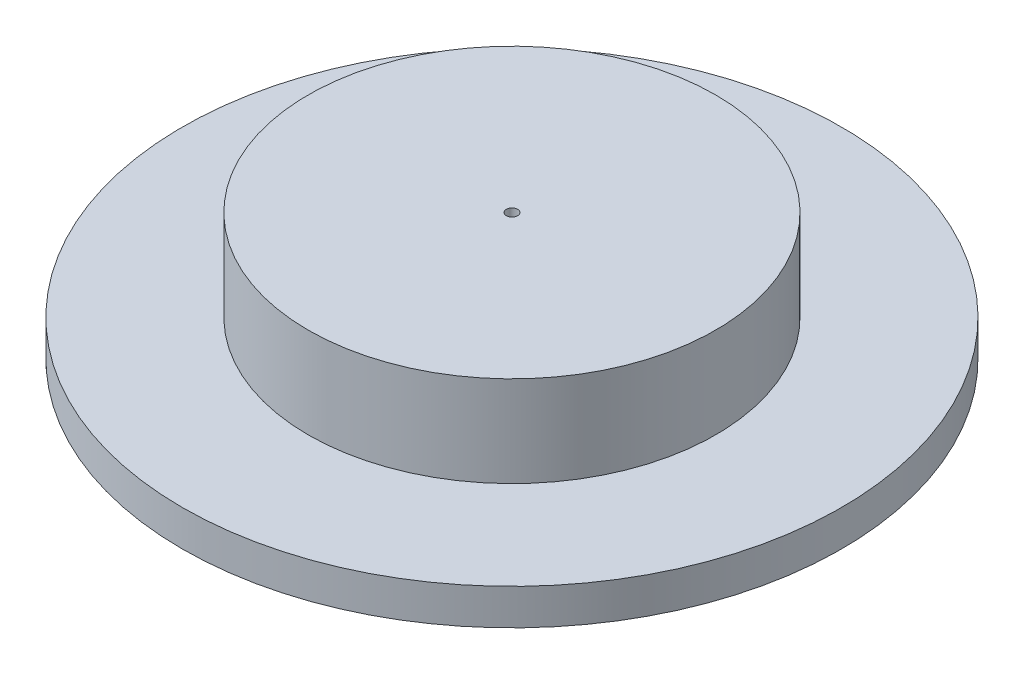
from build123d import *

# Parameters (mm, degrees)
SKETCH1_R                = 69.85
BOSS_EXTRUDE1_DEPTH      = 7.62
SKETCH5_R                = 43.18
BOSS_EXTRUDE2_DEPTH      = 12.7
BOSS_EXTRUDE2_DEPTH_BACK = 14.1478
SKETCH6_R                = 1.190625
CUT_EXTRUDE2_DEPTH       = 17.3228
SKETCH7_R                = 38.1
CUT_EXTRUDE3_DEPTH       = 9.525


with BuildPart() as part:
    # Sketch1 → Boss-Extrude1 (new body)
    with BuildSketch(Plane(origin=(0, 0, 0), x_dir=(1, 0, 0), z_dir=(0, 1, 0))):
        Circle(SKETCH1_R)
    extrude(amount=BOSS_EXTRUDE1_DEPTH)

    # Sketch3 → Revolve1 (revolve)
    with BuildSketch(Plane.XY):
        Polygon((0, 14.1478), (31.873518738, 14.1478), (43.18, 7.62), (0, 7.62), align=None)
    revolve(axis=Axis((0, 7.62, 0), (0, 1, 0)))

    # Sketch5 → Boss-Extrude2 (add, two sides)
    with BuildSketch(Plane(origin=(0, 14.1478, 0), x_dir=(1, 0, 0), z_dir=(0, 1, 0))) as boss_extrude2_sk:
        Circle(SKETCH5_R)
    extrude(amount=BOSS_EXTRUDE2_DEPTH)
    extrude(boss_extrude2_sk.sketch, amount=-BOSS_EXTRUDE2_DEPTH_BACK)

    # Sketch6 → Cut-Extrude2 (cut)
    with BuildSketch(Plane(origin=(0, 26.8478, 0), x_dir=(1, 0, 0), z_dir=(0, 1, 0))):
        Circle(SKETCH6_R)
    extrude(amount=-CUT_EXTRUDE2_DEPTH, mode=Mode.SUBTRACT)

    # Sketch7 → Cut-Extrude3 (cut)
    with BuildSketch(Plane.XZ):
        Circle(SKETCH7_R)
    extrude(amount=-CUT_EXTRUDE3_DEPTH, mode=Mode.SUBTRACT)


solid = part.part
